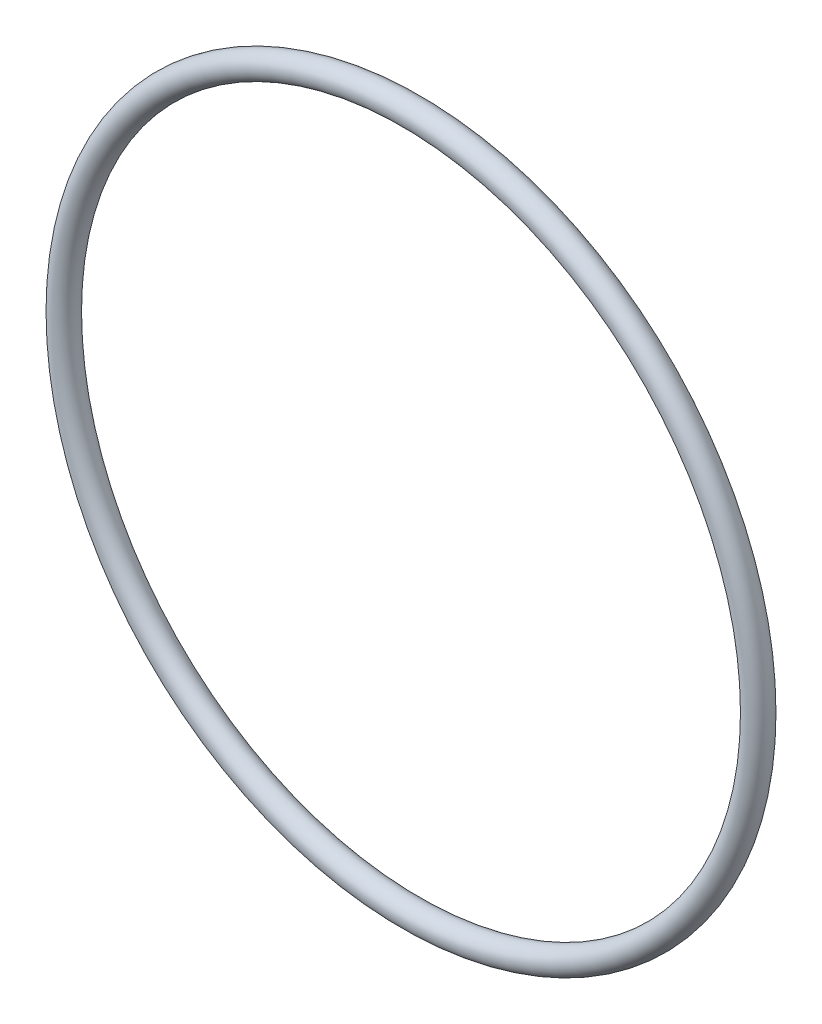
from build123d import *

# Parameters (mm, degrees)
SKETCH1_R = 0.889


with BuildPart() as part:
    # Sketch1 → Revolve1 (revolve)
    with BuildSketch(Plane(origin=(0, 0, 0), x_dir=(0, -1, 0), z_dir=(1, 0, 0))):
        with Locations((24.5618, 0)):
            Circle(SKETCH1_R)
    revolve(axis=Axis((0, 0, 0.889), (0, 0, -1)))


solid = part.part
